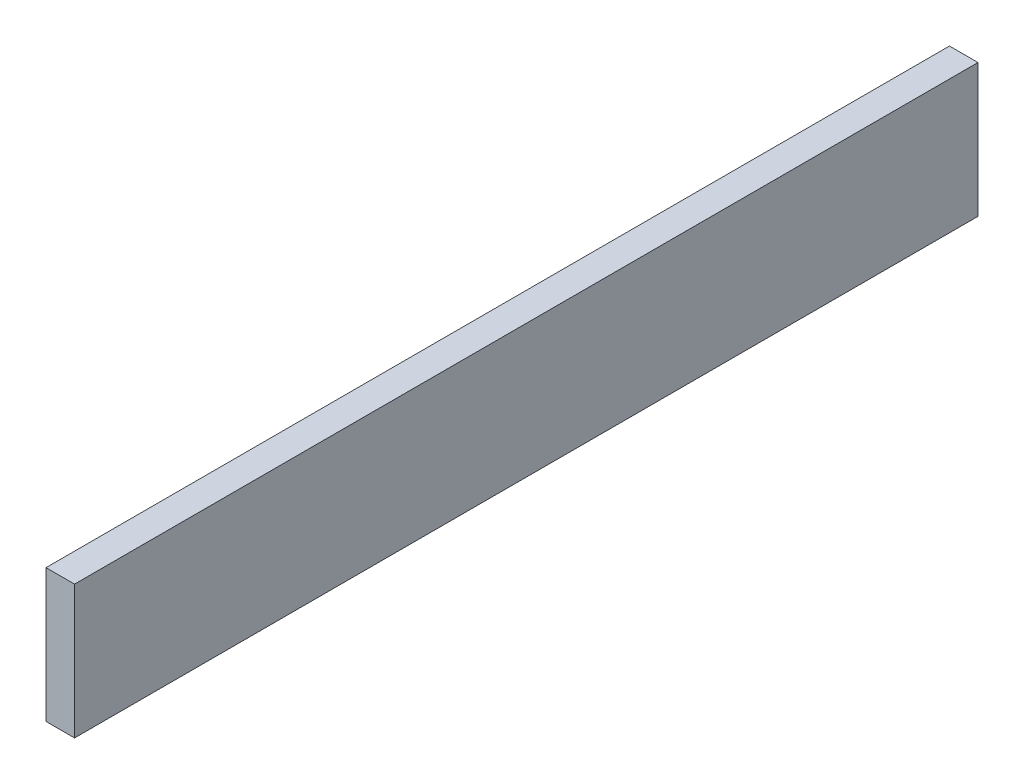
from build123d import *

# Parameters (mm, degrees)
SKETCH1_W           = 602.794090512
SKETCH1_H           = 88.9
BOSS_EXTRUDE1_DEPTH = 19.05


with BuildPart() as part:
    # Sketch1 → Boss-Extrude1 (new body)
    with BuildSketch(Plane(origin=(0, 0, 0), x_dir=(0, 0, -1), z_dir=(1, 0, 0))):
        Rectangle(SKETCH1_W, SKETCH1_H)
    extrude(amount=BOSS_EXTRUDE1_DEPTH)


solid = part.part
